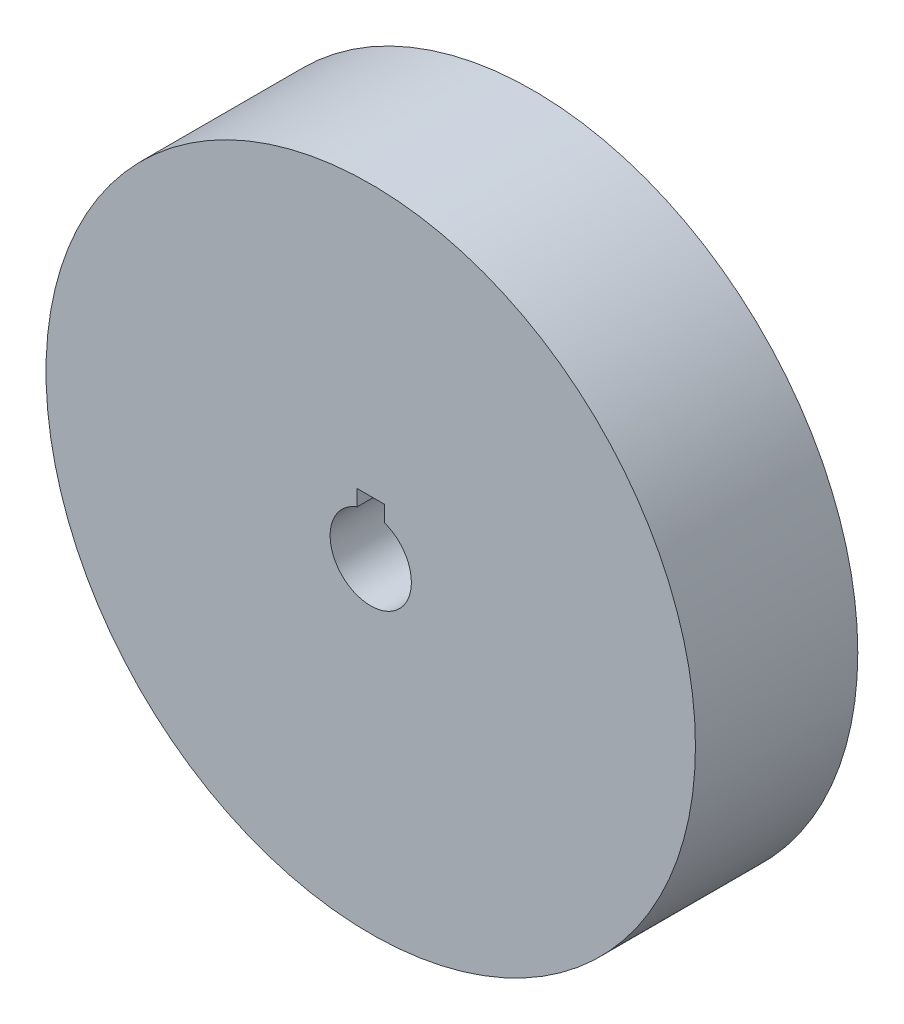
from build123d import *

# Parameters (mm, degrees)
SKETCH1_R           = 76.2
BOSS_EXTRUDE1_DEPTH = 38.1


with BuildPart() as part:
    # Sketch1 → Boss-Extrude1 (new body)
    with BuildSketch(Plane.XY):
        Circle(SKETCH1_R)
        with BuildLine():
            ThreePointArc((9.5377, 0), (-5.502926267, -7.790091385), (-3.1877, 8.989231892))
            Line((-3.1877, 8.989231892), (-3.1877, 12.7254))
            Line((-3.1877, 12.7254), (3.1877, 12.7254))
            Line((3.1877, 12.7254), (3.1877, 8.989231892))
            ThreePointArc((3.1877, 8.989231892), (7.790091385, 5.502926267), (9.5377, 0))
        make_face(mode=Mode.SUBTRACT)
    extrude(amount=BOSS_EXTRUDE1_DEPTH)


solid = part.part
